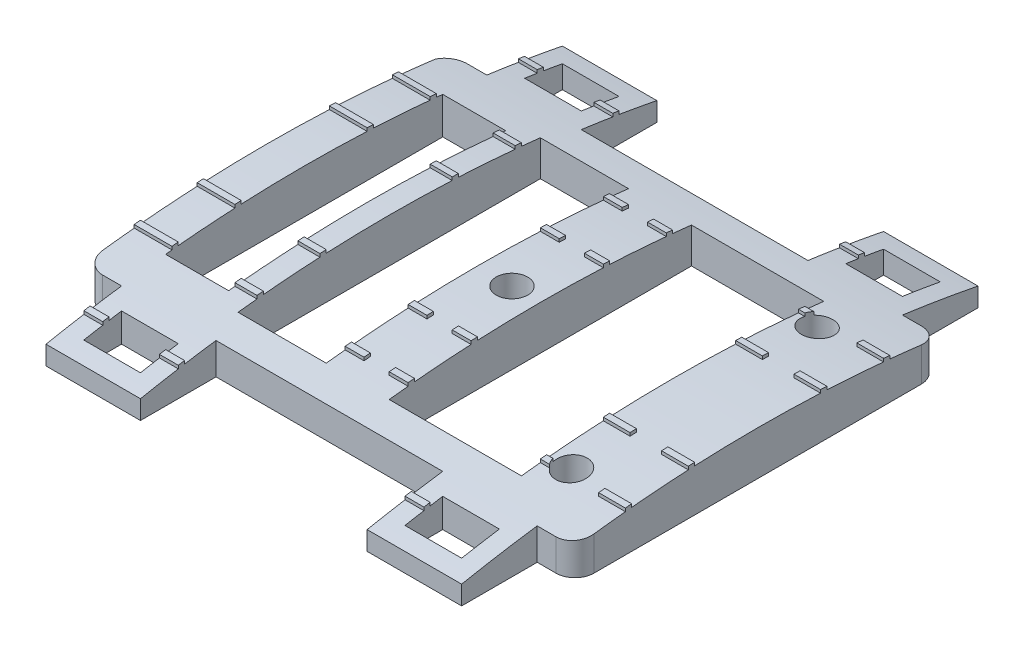
from build123d import *

# Parameters (mm, degrees)
SKETCH1_W           = 9
SKETCH1_H           = 6
BOSS_EXTRUDE1_DEPTH = 10
SKETCH7_R           = 2.5
CUT_EXTRUDE6_DEPTH  = 11
SKETCH8_W           = 21
SKETCH8_H           = 48
SKETCH8_W_2         = 14
SKETCH8_W_3         = 10
SKETCH8_H_2         = 44
CUT_EXTRUDE7_DEPTH  = 11
CUT_EXTRUDE8_DEPTH  = 79
CUT_EXTRUDE9_DEPTH  = 2
CUT_EXTRUDE10_DEPTH = 2.5


with BuildPart() as part:
    # Sketch1 → Boss-Extrude1 (new body)
    with BuildSketch(Plane(origin=(0, 0, 0), x_dir=(1, 0, 0), z_dir=(0, 1, 0))):
        with BuildLine():
            Line((-18, -41), (-18, -29))
            Line((-18, -29), (18, -29))
            Line((18, -29), (18, -41))
            Line((18, -41), (33, -41))
            Line((33, -41), (33, -29))
            Line((33, -29), (36, -29))
            ThreePointArc((36, -29), (38.121320344, -28.121320344), (39, -26))
            Line((39, -26), (39, 26))
            ThreePointArc((39, 26), (38.121320344, 28.121320344), (36, 29))
            Line((36, 29), (33, 29))
            Line((33, 29), (33, 41))
            Line((33, 41), (18, 41))
            Line((18, 41), (18, 29))
            Line((18, 29), (-18, 29))
            Line((-18, 29), (-18, 41))
            Line((-18, 41), (-33, 41))
            Line((-33, 41), (-33, 29))
            Line((-33, 29), (-36.113140033, 29))
            ThreePointArc((-36.113140033, 29), (-37.923065812, 28.392523496), (-39, 26.816112451))
            Line((-39, 26.816112451), (-39, -26))
            ThreePointArc((-39, -26), (-38.121320344, -28.121320344), (-36, -29))
            Line((-36, -29), (-33, -29))
            Line((-33, -29), (-33, -41))
            Line((-33, -41), (-18, -41))
        make_face()
        with Locations((-25.5, -35)):
            Rectangle(SKETCH1_W, SKETCH1_H, mode=Mode.SUBTRACT)
        with Locations((25.5, -35)):
            Rectangle(SKETCH1_W, SKETCH1_H, mode=Mode.SUBTRACT)
        with Locations((-25.5, 35)):
            Rectangle(SKETCH1_W, SKETCH1_H, mode=Mode.SUBTRACT)
        with Locations((25.5, 35)):
            Rectangle(SKETCH1_W, SKETCH1_H, mode=Mode.SUBTRACT)
    extrude(amount=BOSS_EXTRUDE1_DEPTH)

    # Sketch7 → Cut-Extrude6 (cut, through all)
    with BuildSketch(Plane.XZ):
        with Locations((28.95, 19.5)):
            Circle(SKETCH7_R)
        with Locations((28.95, -19.5)):
            Circle(SKETCH7_R)
        Circle(SKETCH7_R)
    extrude(amount=-CUT_EXTRUDE6_DEPTH, mode=Mode.SUBTRACT)

    # Sketch8 → Cut-Extrude7 (cut, through all)
    with BuildSketch(Plane.XZ):
        with Locations((15, 0)):
            Rectangle(SKETCH8_W, SKETCH8_H)
        with Locations((-12.5, 0)):
            Rectangle(SKETCH8_W_2, SKETCH8_H)
        with Locations((-28, 0)):
            Rectangle(SKETCH8_W_3, SKETCH8_H_2)
    extrude(amount=-CUT_EXTRUDE7_DEPTH, mode=Mode.SUBTRACT)

    # Sketch11 → Cut-Extrude8 (cut, through all)
    with BuildSketch(Plane.ZY.offset(39)):
        with BuildLine():
            Line((-41, 10), (-41, 3))
            ThreePointArc((-41, 3), (-37.997288882, 3.569086314), (-34.986690581, 4.094853521))
            Line((-34.986690581, 4.094853521), (-34.986690581, 4.594853521))
            Line((-34.986690581, 4.594853521), (-34, 4.757462554))
            Line((-34, 4.757462554), (-34, 4.257462554))
            ThreePointArc((-34, 4.257462554), (-27.510809379, 5.208475682), (-20.995320336, 5.958424619))
            Line((-20.995320336, 5.958424619), (-20.995320336, 6.458424619))
            Line((-20.995320336, 6.458424619), (-20, 6.555054989))
            Line((-20, 6.555054989), (-20, 6.055054989))
            ThreePointArc((-20, 6.055054989), (-15.502895619, 6.432736451), (-10.998774304, 6.714662454))
            Line((-10.998774304, 6.714662454), (-10.998774304, 7.214662454))
            Line((-10.998774304, 7.214662454), (-10, 7.264158819))
            Line((-10, 7.264158819), (-10, 6.764158819))
            ThreePointArc((-10, 6.764158819), (0, 7), (10, 6.764158819))
            Line((10, 6.764158819), (10, 7.264158819))
            Line((10, 7.264158819), (10.998774304, 7.214662454))
            Line((10.998774304, 7.214662454), (10.998774304, 6.714662454))
            ThreePointArc((10.998774304, 6.714662454), (15.502895619, 6.432736451), (20, 6.055054989))
            Line((20, 6.055054989), (20, 6.555054989))
            Line((20, 6.555054989), (20.995320336, 6.458424619))
            Line((20.995320336, 6.458424619), (20.995320336, 5.958424619))
            ThreePointArc((20.995320336, 5.958424619), (27.510809379, 5.208475682), (34, 4.257462554))
            Line((34, 4.257462554), (34, 4.757462554))
            Line((34, 4.757462554), (34.986690581, 4.594853521))
            Line((34.986690581, 4.594853521), (34.986690581, 4.094853521))
            ThreePointArc((34.986690581, 4.094853521), (37.997288882, 3.569086314), (41, 3))
            Line((41, 3), (41, 10))
            Line((41, 10), (-41, 10))
        make_face()
    extrude(amount=-CUT_EXTRUDE8_DEPTH, mode=Mode.SUBTRACT)

    # Sketch12 → Cut-Extrude9 (cut, symmetric)
    with BuildSketch(Plane.ZY.offset(0.5)):
        with BuildLine():
            Line((-41, 3), (-41, 10.517062119))
            Line((-41, 10.517062119), (41, 10.517062119))
            Line((41, 10.517062119), (41, 3))
            ThreePointArc((41, 3), (0, 7), (-41, 3))
        make_face()
    extrude(amount=CUT_EXTRUDE9_DEPTH, both=True, mode=Mode.SUBTRACT)

    # Sketch13 → Cut-Extrude10 (cut, symmetric)
    with BuildSketch(Plane.ZY.offset(-32.25)):
        with BuildLine():
            Line((-41, 3), (-41, 10.517062119))
            Line((-41, 10.517062119), (41, 10.517062119))
            Line((41, 10.517062119), (41, 3))
            ThreePointArc((41, 3), (0, 7), (-41, 3))
        make_face()
    extrude(amount=CUT_EXTRUDE10_DEPTH, both=True, mode=Mode.SUBTRACT)


solid = part.part
